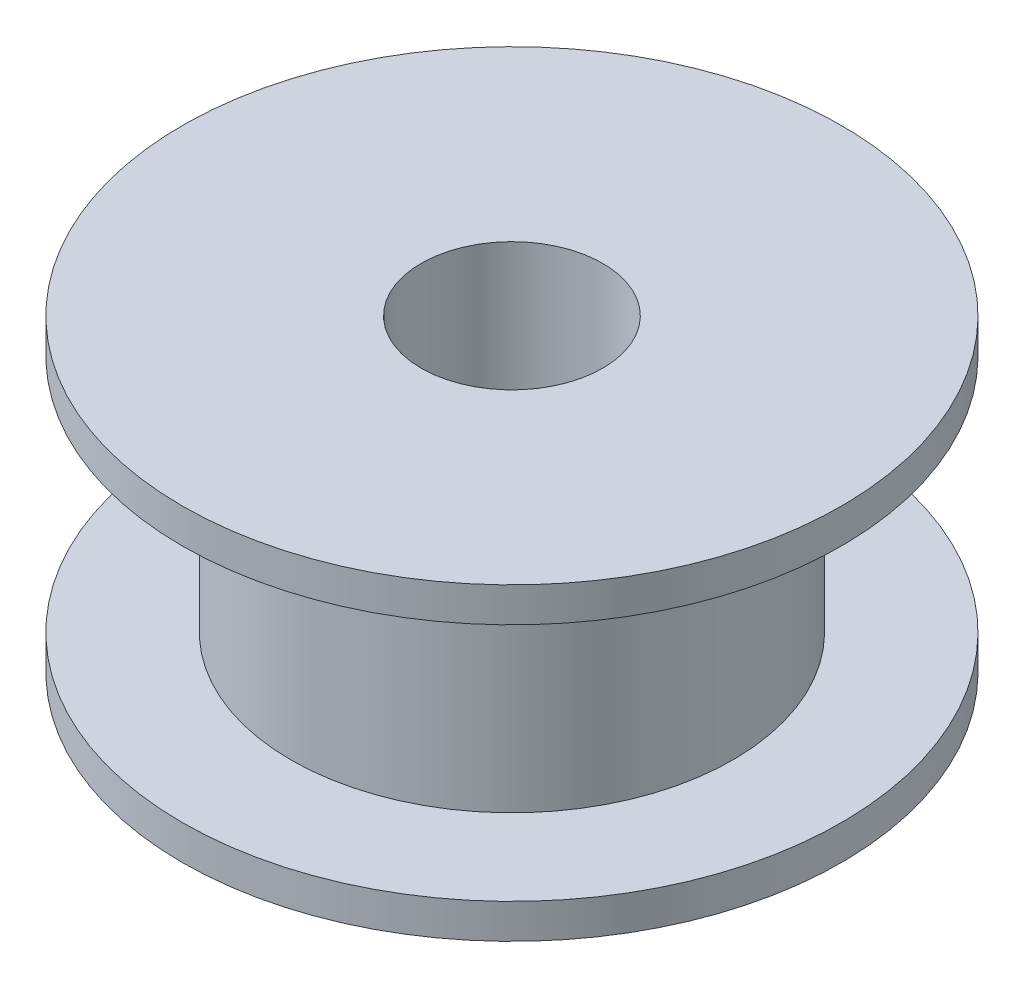
from build123d import *

# Parameters (mm, degrees)
SKETCH1_R           = 8.945
BOSS_EXTRUDE1_DEPTH = 0.94
SKETCH2_R           = 6
BOSS_EXTRUDE2_DEPTH = 6.5
SKETCH3_R           = 8.945
BOSS_EXTRUDE3_DEPTH = 0.94
SKETCH4_R           = 2.465
CUT_EXTRUDE1_DEPTH  = 9.38


with BuildPart() as part:
    # Sketch1 → Boss-Extrude1 (new body)
    with BuildSketch(Plane(origin=(0, 0, 0), x_dir=(1, 0, 0), z_dir=(0, 1, 0))):
        Circle(SKETCH1_R)
    extrude(amount=BOSS_EXTRUDE1_DEPTH)

    # Sketch2 → Boss-Extrude2 (add)
    with BuildSketch(Plane(origin=(0, 0.94, 0), x_dir=(1, 0, 0), z_dir=(0, 1, 0))):
        Circle(SKETCH2_R)
    extrude(amount=BOSS_EXTRUDE2_DEPTH)

    # Sketch3 → Boss-Extrude3 (add)
    with BuildSketch(Plane(origin=(0, 7.44, 0), x_dir=(1, 0, 0), z_dir=(0, 1, 0))):
        Circle(SKETCH3_R)
    extrude(amount=BOSS_EXTRUDE3_DEPTH)

    # Sketch4 → Cut-Extrude1 (cut, through all)
    with BuildSketch(Plane(origin=(0, 8.38, 0), x_dir=(1, 0, 0), z_dir=(0, 1, 0))):
        Circle(SKETCH4_R)
    extrude(amount=-CUT_EXTRUDE1_DEPTH, mode=Mode.SUBTRACT)


solid = part.part
